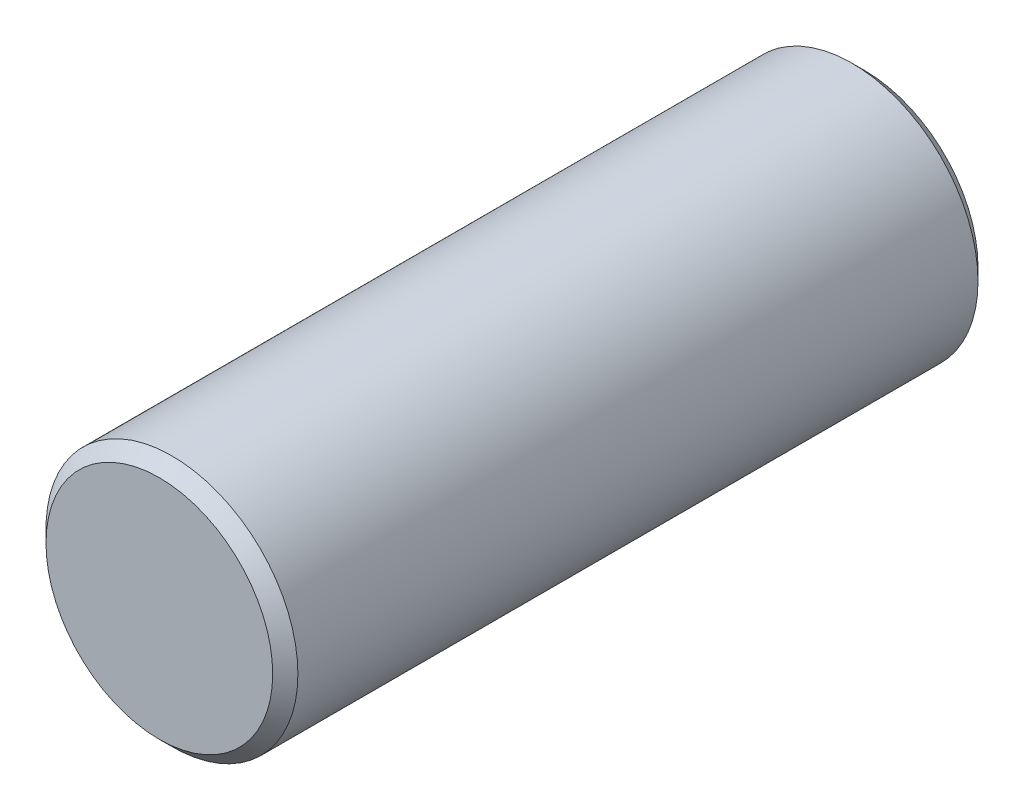
from build123d import *

# Parameters (mm, degrees)
SKETCH1_R           = 5
BOSS_EXTRUDE1_DEPTH = 28
CHAMFER1_SIZE       = 0.5


with BuildPart() as part:
    # Sketch1 → Boss-Extrude1 (new body)
    with BuildSketch(Plane.XY):
        Circle(SKETCH1_R)
    extrude(amount=BOSS_EXTRUDE1_DEPTH)

    # Chamfer1
    chamfer1_edges = [part.edges().sort_by_distance(p)[0] for p in [
        (-5, 0, 0),
        (-5, 0, 28),
    ]]
    chamfer(chamfer1_edges, length=CHAMFER1_SIZE)


solid = part.part
